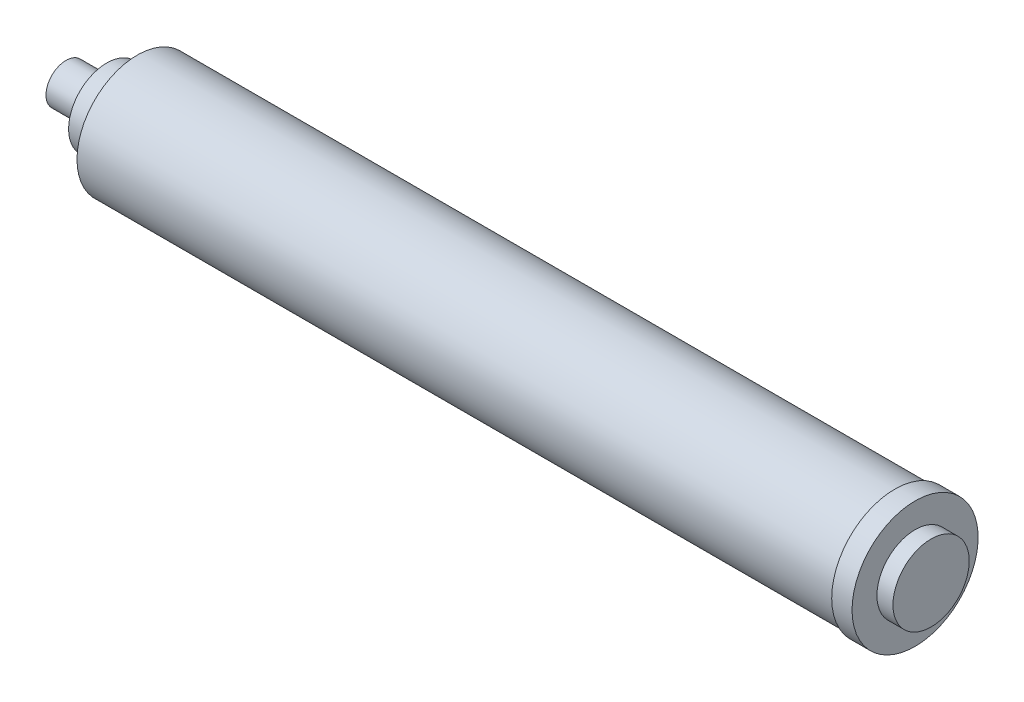
from build123d import *

# Parameters (mm, degrees)
ESQUISSE4_R        = 23.8
BOSS_EXTRU_2_DEPTH = 19.1
ESQUISSE8_R        = 12.5
BOSS_EXTRU_3_DEPTH = 25.4
ESQUISSE9_R        = 23.8
BOSS_EXTRU_4_DEPTH = 10


with BuildPart() as part:
    # Esquisse3 → Révolution1 (revolve)
    with BuildSketch(Plane.XY):
        Polygon((0, 0), (0, 39.35), (-12.7, 39.35), (-12.7, 37.65), (-485.5, 37.65), (-485.5, 0), align=None)
    revolve(axis=Axis((-619.271971496, 0, 0), (1, 0, 0)))

    # Esquisse4 → Boss.-Extru.2 (add)
    with BuildSketch(Plane.ZY.offset(485.5)):
        Circle(ESQUISSE4_R)
    extrude(amount=BOSS_EXTRU_2_DEPTH)

    # Esquisse8 → Boss.-Extru.3 (add)
    with BuildSketch(Plane.ZY.offset(504.6)):
        Circle(ESQUISSE8_R)
    extrude(amount=BOSS_EXTRU_3_DEPTH)

    # Esquisse9 → Boss.-Extru.4 (add)
    with BuildSketch(Plane(origin=(0, 0, 0), x_dir=(0, 0, -1), z_dir=(1, 0, 0))):
        Circle(ESQUISSE9_R)
    extrude(amount=BOSS_EXTRU_4_DEPTH)


solid = part.part
